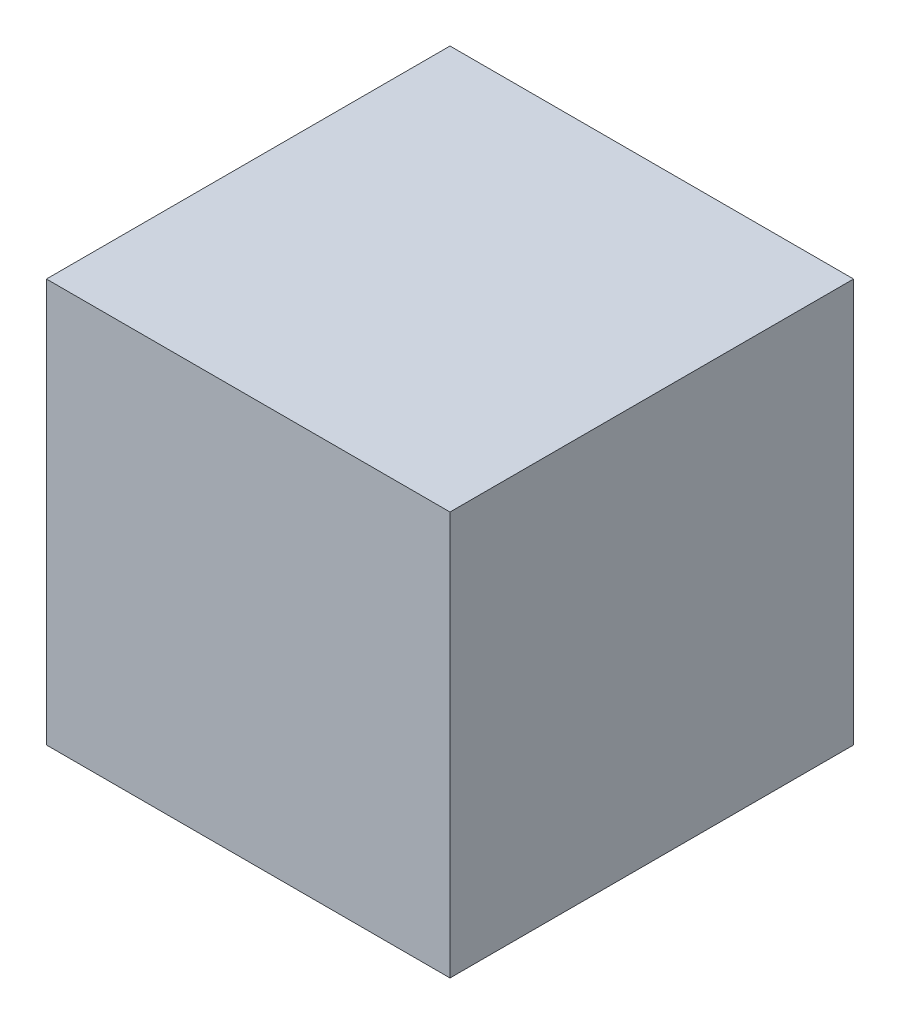
from build123d import *

# Parameters (mm, degrees)
SKETCH1_W           = 50.8
SKETCH1_H           = 50.8
BOSS_EXTRUDE1_DEPTH = 25.4


with BuildPart() as part:
    # Sketch1 → Boss-Extrude1 (new body, symmetric)
    with BuildSketch(Plane(origin=(0, 0, 0), x_dir=(1, 0, 0), z_dir=(0, 1, 0))):
        Rectangle(SKETCH1_W, SKETCH1_H)
    extrude(amount=BOSS_EXTRUDE1_DEPTH, both=True)


solid = part.part
